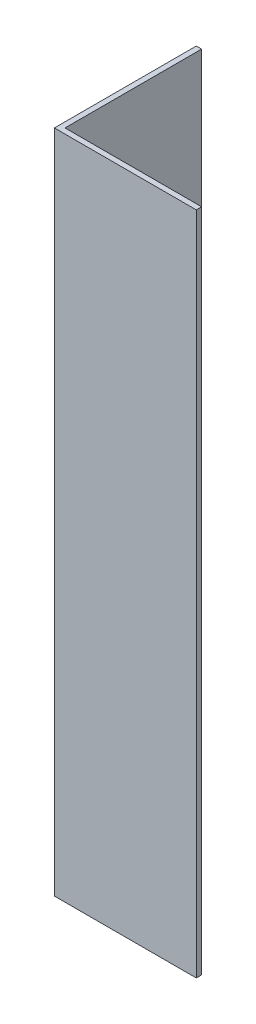
from build123d import *

# Parameters (mm, degrees)
EXTRUDE_1_DEPTH = 93.75


with BuildPart() as part:
    # Эскиз1 → Бобышка-Вытянуть1 (new body)
    with BuildSketch(Plane(origin=(0, 0, 0), x_dir=(1, 0, 0), z_dir=(0, 1, 0))):
        Polygon((0, 0), (0, 20), (0.75, 20), (0.75, 0.75), (20, 0.75), (20, 0), align=None)
    extrude(amount=EXTRUDE_1_DEPTH)


solid = part.part
